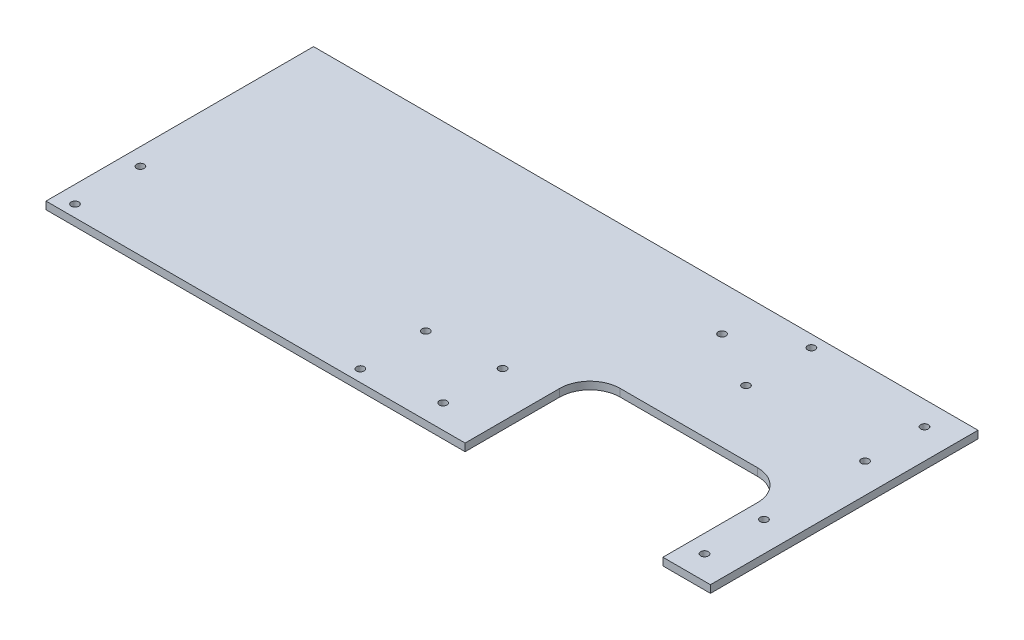
from build123d import *

# Parameters (mm, degrees)
SKETCH1_W           = 558.8
SKETCH1_H           = 225
BOSS_EXTRUDE1_DEPTH = 6.35
SKETCH2_W           = 166.35
SKETCH2_H           = 143.7
CUT_EXTRUDE1_DEPTH  = 7.35
FILLET1_R           = 25.4
SKETCH3_R           = 3.2
CUT_EXTRUDE2_DEPTH  = 7.35


with BuildPart() as part:
    # Sketch1 → Boss-Extrude1 (new body)
    with BuildSketch(Plane(origin=(0, 0, 0), x_dir=(1, 0, 0), z_dir=(0, 1, 0))):
        Rectangle(SKETCH1_W, SKETCH1_H)
    extrude(amount=BOSS_EXTRUDE1_DEPTH)

    # Sketch2 → Cut-Extrude1 (cut, through all)
    with BuildSketch(Plane(origin=(0, 6.35, 0), x_dir=(1, 0, 0), z_dir=(0, 1, 0))):
        with Locations((156.225, -79.35)):
            Rectangle(SKETCH2_W, SKETCH2_H)
    extrude(amount=-CUT_EXTRUDE1_DEPTH, mode=Mode.SUBTRACT)

    # Fillet1
    fillet1_edges = [part.edges().sort_by_distance(p)[0] for p in [
        (239.4, 3.175, 7.5),
        (73.05, 3.175, 7.5),
    ]]
    fillet(fillet1_edges, radius=FILLET1_R)

    # Sketch3 → Cut-Extrude2 (cut, through all)
    with BuildSketch(Plane(origin=(0, 6.35, 0), x_dir=(1, 0, 0), z_dir=(0, 1, 0))):
        with Locations((-265.017168878, -102.5)):
            Circle(SKETCH3_R)
        with Locations((-265.017168878, -47.5)):
            Circle(SKETCH3_R)
        with Locations((-25.017168878, -47.5)):
            Circle(SKETCH3_R)
        with Locations((-25.017168878, -102.5)):
            Circle(SKETCH3_R)
        with Locations((101.644095195, 75)):
            Circle(SKETCH3_R)
        with Locations((149.275492403, 102.5)):
            Circle(SKETCH3_R)
        with Locations((149.275492403, 47.5)):
            Circle(SKETCH3_R)
        with Locations((254.4, 92.5)):
            Circle(SKETCH3_R)
        with Locations((254.4, 42.5)):
            Circle(SKETCH3_R)
        with Locations((254.4, -42.5)):
            Circle(SKETCH3_R)
        with Locations((254.4, -92.5)):
            Circle(SKETCH3_R)
        with Locations((34.575, -42.5)):
            Circle(SKETCH3_R)
        with Locations((34.575, -92.5)):
            Circle(SKETCH3_R)
    extrude(amount=-CUT_EXTRUDE2_DEPTH, mode=Mode.SUBTRACT)


solid = part.part
